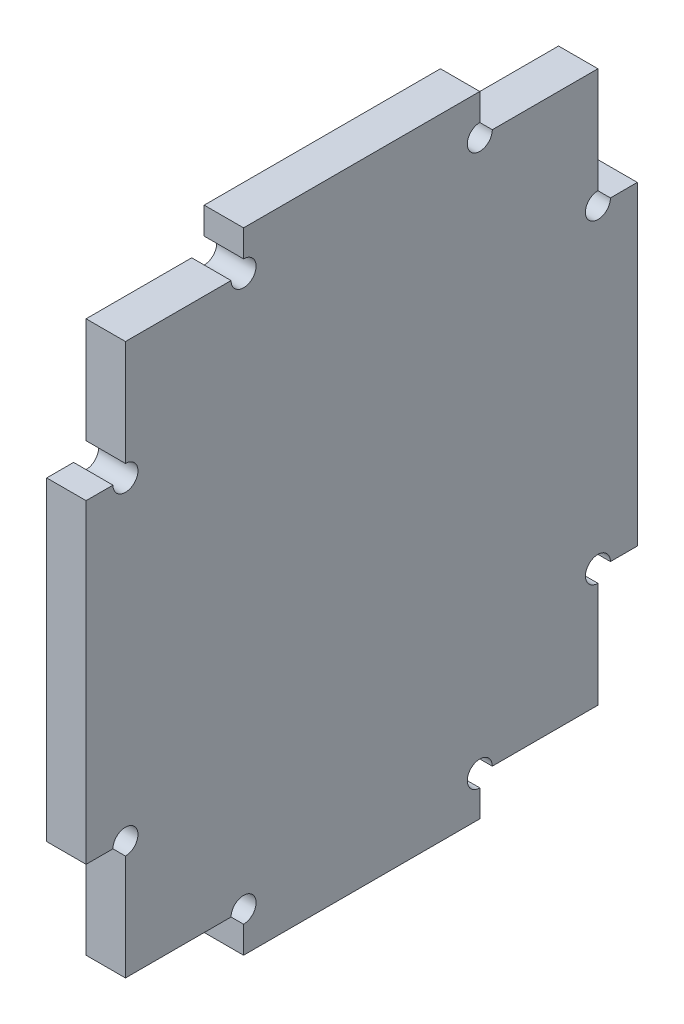
from build123d import *

# Parameters (mm, degrees)
SKETCH1_W                                = 70
SKETCH1_H                                = 80
BOSS_EXTRUDE1_DEPTH                      = 5
CUT_EXTRUDE1_START                       = -6
CUT_EXTRUDE1_DEPTH                       = 7
MIRROR1_START                            = -6
MIRROR1_AT_THE_SECOND_PLANE_COPY_1_DEPTH = 7
SKETCH4_R                                = 1.5875
CUT_EXTRUDE2_DEPTH                       = 6


with BuildPart() as part:
    # Sketch1 → Boss-Extrude1 (new body)
    with BuildSketch(Plane(origin=(0, 0, 0), x_dir=(0, 0, -1), z_dir=(1, 0, 0))):
        Rectangle(SKETCH1_W, SKETCH1_H)
    extrude(amount=BOSS_EXTRUDE1_DEPTH)

    # Sketch3 → Cut-Extrude1 (cut)
    with BuildSketch(Plane(origin=(5, 0, 0), x_dir=(0, 0, -1), z_dir=(1, 0, 0)).offset(CUT_EXTRUDE1_START)):
        Polygon((-35, 20), (-30, 20), (-30, 35), (-15, 35), (-15, 40), (-35, 40), align=None)
    cut_extrude1 = extrude(amount=CUT_EXTRUDE1_DEPTH, mode=Mode.SUBTRACT)

    # Mirror1: Cut-Extrude1 across plane
    add(cut_extrude1.mirror(Plane.XY), mode=Mode.SUBTRACT)

    # Mirror1 at the second plane: Cut-Extrude1 across plane
    add(cut_extrude1.mirror(Plane.ZX), mode=Mode.SUBTRACT)

    # Mirror1 at the second plane copy 1 sketc → Mirror1 at the second plane copy 1 (cut)
    with BuildSketch(Plane(origin=(5, 0, 0), x_dir=(0, 0, 1), z_dir=(1, 0, 0)).offset(MIRROR1_START)):
        Polygon((-35, 20), (-30, 20), (-30, 35), (-15, 35), (-15, 40), (-35, 40), align=None)
    extrude(amount=MIRROR1_AT_THE_SECOND_PLANE_COPY_1_DEPTH, mode=Mode.SUBTRACT)

    # Sketch4 → Cut-Extrude2 (cut, through all)
    with BuildSketch(Plane(origin=(5, 0, 0), x_dir=(0, 0, -1), z_dir=(1, 0, 0))):
        with Locations((-30, 20)):
            Circle(SKETCH4_R)
        with Locations((-15, 35)):
            Circle(SKETCH4_R)
        with Locations((15, 35)):
            Circle(SKETCH4_R)
        with Locations((30, 20)):
            Circle(SKETCH4_R)
        with Locations((30, -20)):
            Circle(SKETCH4_R)
        with Locations((15, -35)):
            Circle(SKETCH4_R)
        with Locations((-15, -35)):
            Circle(SKETCH4_R)
        with Locations((-30, -20)):
            Circle(SKETCH4_R)
    extrude(amount=-CUT_EXTRUDE2_DEPTH, mode=Mode.SUBTRACT)


solid = part.part
